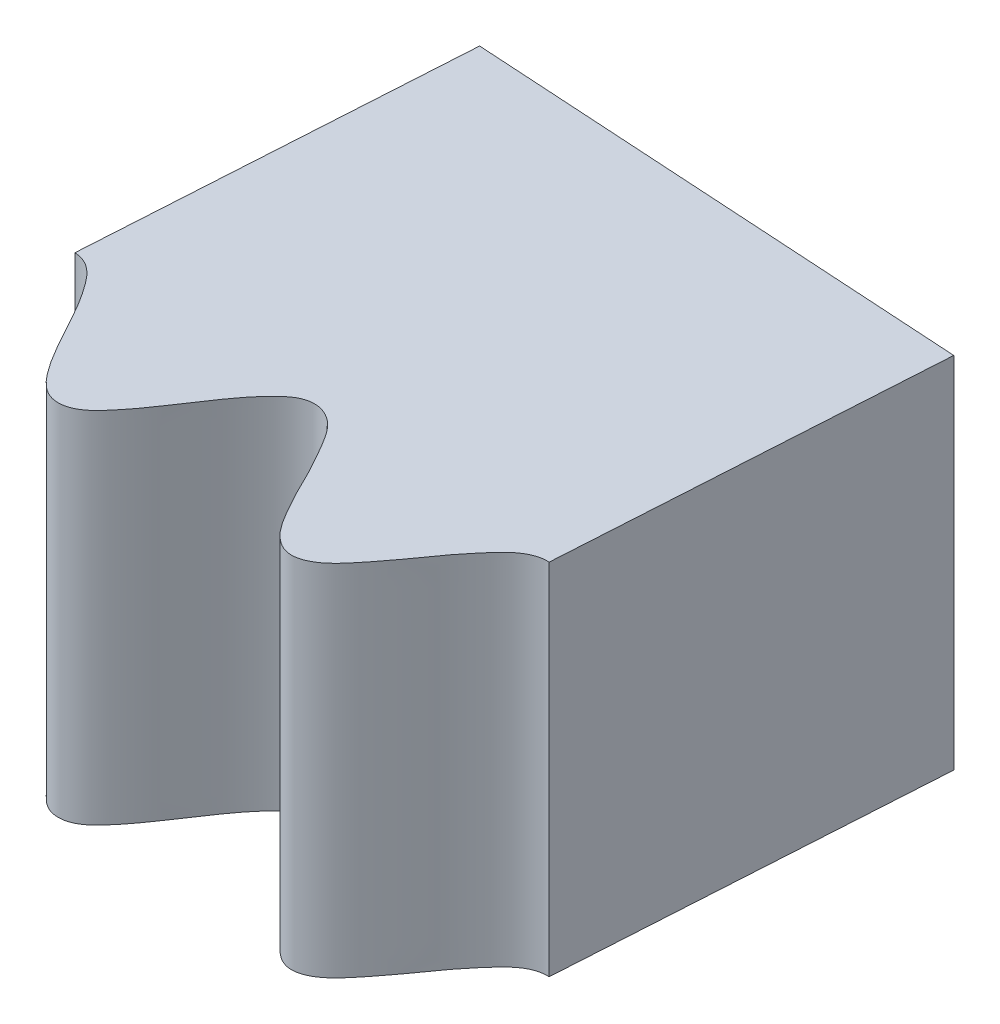
from build123d import *

# Parameters (mm, degrees)
BOSS_EXTRUDE1_DEPTH     = 4
CUT_EXTRUDE2_DEPTH      = 121.274685761
CUT_EXTRUDE2_DEPTH_BACK = 121.274685761
CUT_EXTRUDE1_DEPTH      = 121.251263566
CUT_EXTRUDE1_DEPTH_BACK = 121.251263566
CUT_EXTRUDE3_DEPTH      = 86.436238869
CUT_EXTRUDE3_DEPTH_BACK = 86.436238869


with BuildPart() as part:
    # Sketch1 → Boss-Extrude1 (new body)
    with BuildSketch(Plane(origin=(0, 0, 0), x_dir=(1, 0, 0), z_dir=(0, 1, 0))):
        with BuildLine():
            Line((0, 80.000000001), (0, 85))
            ThreePointArc((0, 85), (60.104076401, 60.1040764), (85, -1e-09))
            Line((85, -1e-09), (79.999999998, -1e-09))
            add(Edge.make_bspline(
                [(79.999999998, -1e-09), (80.045245689, 0.02681226), (80.136037734, 0.080585238), (80.334864822, 0.198976063), (80.508626367, 0.334195881), (80.753018834, 0.526004454), (80.781258066, 0.882635658), (80.459939981, 1.103766583), (80.198460731, 1.283917746), (79.891541965, 1.44569599), (79.626061012, 1.608937298), (79.381240219, 1.765048438), (79.172216457, 2.009659752), (79.273864616, 2.315204156), (79.522900146, 2.501891378), (79.779396548, 2.690833874), (80.088618496, 2.870717889), (80.350662212, 3.06392161), (80.600727145, 3.250938184), (80.728185798, 3.543289402), (80.560379021, 3.7880225), (80.345179038, 3.931341964), (80.120721915, 4.068429585), (79.89920724, 4.181739561), (79.689481725, 4.291683981), (79.493561265, 4.401042279), (79.320325812, 4.516660534), (79.117921665, 4.674691893), (79.055561951, 4.977869251), (79.314830423, 5.21984864), (79.558069697, 5.415473192), (79.844013051, 5.601917948), (80.112906693, 5.801539522), (80.362427565, 5.986752763), (80.592348669, 6.31020266), (80.364696993, 6.632082897), (80.06923695, 6.778689274), (79.775461705, 6.943332918), (79.456163372, 7.078188344), (79.194107524, 7.23317743), (78.920113249, 7.399727688), (78.842032953, 7.699819435), (79.026214893, 7.933115242), (79.22518077, 8.105822663), (79.445296584, 8.281637195), (79.703399896, 8.456254619), (79.938325413, 8.670021885), (80.221750602, 8.878963537), (80.274522022, 9.245568073), (80.009478642, 9.45007403), (79.793463584, 9.573613375), (79.549134368, 9.686889429), (79.309501257, 9.790364021), (79.065278691, 9.897929864), (78.840566054, 10.020105278), (78.602382115, 10.171484613), (78.52636273, 10.451978162), (78.702904597, 10.68553378), (78.886641465, 10.861173834), (79.091562303, 11.031391774), (79.297355716, 11.193689896), (79.503615131, 11.361173074), (79.689475466, 11.539715158), (79.867832233, 11.742233628), (79.887570214, 12.013300522), (79.69795305, 12.196804418), (79.495414452, 12.309626055), (79.268938989, 12.414026463), (79.025567335, 12.511861748), (78.761696132, 12.611495714), (78.504820249, 12.734830825), (78.231668231, 12.869982942), (78.098942061, 13.163008392), (78.281482966, 13.428010238), (78.469131216, 13.616425559), (78.681740408, 13.805685544), (78.893029523, 13.982393534), (79.105112269, 14.174667367), (79.288055774, 14.362719654), (79.479145508, 14.659947643), (79.27624125, 14.982158335), (78.955651284, 15.091459308), (78.663263398, 15.226924234), (78.371081923, 15.315930733), (78.111445613, 15.421477815), (77.872238358, 15.527590176), (77.636661624, 15.707177089), (77.646875585, 16.01419058), (77.856109832, 16.245424503), (78.062730074, 16.469057789), (78.32259806, 16.688835125), (78.554988673, 16.926051649), (78.778839306, 17.14829737), (78.912075634, 17.485848925), (78.670934329, 17.73028689), (78.41256561, 17.835491137), (78.150421173, 17.934616323), (77.904723053, 18.011215448), (77.664803855, 18.081746707), (77.426081767, 18.19040535), (77.111976282, 18.287933946), (76.969646897, 18.648997405), (77.248828953, 18.953516243), (77.438560069, 19.182392158), (77.686338139, 19.408332255), (77.902653965, 19.637457063), (78.094717908, 19.853352774), (78.24611152, 20.145230603), (78.082037928, 20.43001587), (77.780860894, 20.544801821), (77.484194275, 20.655472153), (77.136168812, 20.736047929), (76.827844649, 20.842194969), (76.527993938, 20.939774349), (76.298113812, 21.187091884), (76.410480338, 21.499269505), (76.594970673, 21.712178007), (76.78630337, 21.939912385), (77.021285595, 22.163443331), (77.218792317, 22.419877421), (77.461893887, 22.677746331), (77.448303497, 23.045296267), (77.153076804, 23.199929754), (76.918728598, 23.284193749), (76.658513621, 23.353272647), (76.404526228, 23.413581151), (76.145343984, 23.477098297), (75.902827103, 23.558398368), (75.641975749, 23.666117187), (75.518403779, 23.929148978), (75.65170721, 24.189812442), (75.802153061, 24.394689745), (75.974402682, 24.597905805), (76.148886849, 24.79347391), (76.322929574, 24.994229213), (76.474962764, 25.20233315), (76.615442928, 25.432746237), (76.587810773, 25.703122481), (76.369209202, 25.850911864), (76.150156349, 25.926849029), (75.908992617, 25.990336309), (75.652329406, 26.044424211), (75.375165743, 26.096723761), (75.100775465, 26.173579105), (74.80830432, 26.259245608), (74.626711224, 26.524771685), (74.760461834, 26.817445453), (74.912541309, 27.035583098), (75.089055839, 27.258886997), (75.266449977, 27.469600367), (75.441922708, 27.69578091), (75.589431953, 27.912744067), (75.726005506, 28.238638879), (75.470232521, 28.520720511), (75.135533121, 28.572691094), (74.824064027, 28.65532538), (74.520865628, 28.692242889), (74.246845719, 28.751101102), (73.992846341, 28.814063473), (73.729663607, 28.950014587), (73.686410062, 29.254137489), (73.852312222, 29.518191595), (74.016959925, 29.774306617), (74.234715999, 30.035870644), (74.422383859, 30.309837523), (74.604241134, 30.567578086), (74.67683809, 30.923137721), (74.396914056, 31.121988375), (74.124202012, 31.180729076), (73.848827231, 31.232827424), (73.593560519, 31.265597805), (73.345038608, 31.293396004), (73.091074869, 31.358950222), (72.76480569, 31.400453295), (72.561940597, 31.731316151), (72.784002108, 32.079688118), (72.931106897, 32.338033356), (73.135886574, 32.603567126), (73.309128972, 32.866773862), (73.460785136, 33.112741187), (73.559194686, 33.42647396), (73.348161297, 33.678441618), (73.031627448, 33.73918487), (72.72025016, 33.796658253), (72.363520149, 33.815575914), (72.041447883, 33.866570414), (71.729208096, 33.910598814), (71.459874127, 34.114240775), (71.516324478, 34.441187959), (71.661040816, 34.682898313), (71.80992108, 34.940397468), (72.002517656, 35.201336712), (72.152494495, 35.488171675), (72.347124339, 35.784337121), (72.269916041, 36.143943201), (71.952322682, 36.24496188), (71.706902462, 36.287251577), (71.43864531, 36.310095155), (71.178044095, 36.325382989), (70.911769775, 36.342928643), (70.658819662, 36.380880969), (70.383226049, 36.441666935), (70.215856424, 36.679244634), (70.30187094, 36.959095932), (70.414454611, 37.186985337), (70.548799274, 37.417024921), (70.686672589, 37.639920765), (70.823210422, 37.867848345), (70.936797017, 38.099191003), (71.035132159, 38.350497721), (70.960969456, 38.611968069), (70.720025578, 38.719552435), (70.491114279, 38.756297815), (70.242589916, 38.776942938), (69.98043373, 38.785640025), (69.698399085, 38.789016061), (69.41483162, 38.817056429), (69.111927938, 38.850634383), (68.886985529, 39.080593212), (68.967881901, 39.392046158), (69.079771742, 39.633278126), (69.214828304, 39.883840964), (69.352937434, 40.122157293), (69.4864685, 40.375372164), (69.594061493, 40.614653878), (69.671969145, 40.959313357), (69.371098967, 41.192695036), (69.032459802, 41.185756102), (68.71137334, 41.213048998), (68.406370528, 41.196755692), (68.126293019, 41.207136891), (67.865219077, 41.225035745), (67.582427167, 41.313221045), (67.487020059, 41.605211192), (67.60454995, 41.894065873), (67.722220841, 42.174872609), (67.89125167, 42.470292045), (68.028488827, 42.772654534), (68.162837614, 43.058114391), (68.172571957, 43.420785418), (67.862402258, 43.568177511), (67.583549507, 43.57823387), (67.303602841, 43.582910059), (66.99345828, 43.564723409), (66.694278866, 43.55702837), (66.424037364, 43.563845442), (66.115753527, 43.641555056), (65.980663422, 43.915215302), (66.101455704, 44.223781199), (66.211119573, 44.515165677), (66.361456012, 44.806054129), (66.48903129, 45.098499213), (66.594418223, 45.365584252), (66.637383714, 45.692265401), (66.385539876, 45.903449201), (66.063431871, 45.908498879), (65.746698606, 45.910903424), (65.392164192, 45.867660302), (65.066097446, 45.861914582), (64.75097087, 45.851071979), (64.450360211, 46.004843225), (64.449182672, 46.33662998), (64.549725793, 46.599795473), (64.651630997, 46.879236635), (64.795989494, 47.169655102), (64.893879721, 47.478175888), (65.034123987, 47.803638888), (64.895643776, 48.144374734), (64.565333634, 48.188709168), (64.316298385, 48.187739634), (64.04814991, 48.163653793), (63.78885311, 48.133456448), (63.523577324, 48.104497492), (63.267879739, 48.097948911), (62.98591764, 48.109955072), (62.779835801, 48.314860003), (62.815947897, 48.605395994), (62.887248588, 48.849373196), (62.9796063, 49.099246668), (63.076679553, 49.342697673), (63.17156386, 49.590872067), (63.243252589, 49.838424215), (63.296454845, 50.102988739), (63.17801499, 50.347608546), (62.922049762, 50.411718998), (62.690235372, 50.408156103), (62.441901664, 50.385331778), (62.182217986, 50.348373792), (61.903881839, 50.302723737), (61.619753243, 50.281097135), (61.315620597, 50.261566292), (61.054163638, 50.448970691), (61.079747775, 50.769739474), (61.148048266, 51.026736054), (61.237543235, 51.296944603), (61.332170984, 51.555622776), (61.419703105, 51.828178157), (61.4841107, 52.082508), (61.50098524, 52.435459795), (61.164159709, 52.613050426), (60.831870053, 52.547412628), (60.510922484, 52.518535224), (60.213382179, 52.449525403), (59.935758038, 52.411115833), (59.675540291, 52.383404096), (59.381734936, 52.421149801), (59.237066838, 52.69212413), (59.302667872, 52.997028108), (59.369753434, 53.293936256), (59.484989475, 53.614351336), (59.567501467, 53.93570383), (59.650488663, 54.240610984), (59.596680581, 54.598700646), (59.266395013, 54.691392062), (58.988097032, 54.649340325), (58.716336171, 54.613994972), (58.4034352, 54.522830082), (58.08058627, 54.493558174), (57.692145499, 54.368585848), (57.329587976, 54.627991743), (57.425029251, 55.043431179), (57.471237245, 55.329001576), (57.574869246, 55.652697061), (57.646602495, 55.957154431), (57.705475834, 56.24115886), (57.690440693, 56.569205491), (57.406058763, 56.734010088), (57.087774426, 56.682697239), (56.775559955, 56.630292284), (56.433849325, 56.52601138), (56.113771889, 56.463801221), (55.805297995, 56.398370064), (55.482559706, 56.497618404), (55.423781795, 56.824152619), (55.477101676, 57.100783628), (55.528933062, 57.393672913), (55.620668354, 57.704747888), (55.663497053, 58.025579492), (55.745094781, 58.370451402), (55.549550167, 58.681963741), (55.21655962, 58.668266946), (54.971476115, 58.624067591), (54.711583889, 58.553784189), (54.461470101, 58.479019187), (54.205253121, 58.404435527), (53.954577306, 58.353585014), (53.674813997, 58.31644657), (53.436281637, 58.482452799), (53.421394062, 58.774845695), (53.44924534, 59.02749757), (53.496809857, 59.289612651), (53.550133526, 59.546221682), (53.600481296, 59.807102236), (53.628093932, 60.063342128), (53.634546779, 60.333125796), (53.475428509, 60.553462414), (53.212219304, 60.572150989), (52.984545386, 60.528388076), (52.743947827, 60.462787808), (52.494627015, 60.3812977), (52.228446468, 60.288008607), (51.952389844, 60.217372149), (51.656269151, 60.145325943), (51.366241879, 60.284481724), (51.335736421, 60.604819947), (51.358372286, 60.869772427), (51.399586403, 61.151416539), (51.44785755, 61.422596745), (51.486731117, 61.706211191), (51.505996303, 61.967861454), (51.461325044, 62.318381351), (51.09877836, 62.434784842), (50.782934814, 62.312442736), (50.471877669, 62.228272084), (50.190841099, 62.108643347), (49.924104445, 62.022608378), (49.672652083, 61.950131307), (49.376755818, 61.936284805), (49.187231355, 62.178021074), (49.198889742, 62.489684375), (49.213398565, 62.793731107), (49.271244417, 63.12928889), (49.296700591, 63.460087375), (49.325480454, 63.77477288), (49.21030822, 64.118078679), (48.868944737, 64.152008417), (48.602176935, 64.062269604), (48.340682387, 63.980270448), (48.048365703, 63.836155874), (47.735504587, 63.751266543), (47.37466632, 63.560740796), (46.9725715, 63.753248279), (46.994422507, 64.178949461), (46.990339718, 64.468205335), (47.036188185, 64.804978667), (47.053963178, 65.117266993), (47.062625247, 65.407180004), (46.990853823, 65.727632045), (46.682174276, 65.840550486), (46.377635776, 65.7347477), (46.079264569, 65.62892342), (45.760853481, 65.466889349), (45.456441421, 65.350043439), (45.16401594, 65.232040398), (44.828946477, 65.273738017), (44.714359464, 65.585104767), (44.718832825, 65.866792029), (44.719017085, 66.164232094), (44.75534111, 66.486510807), (44.741807321, 66.809905383), (44.762279017, 67.163707211), (44.515611616, 67.436531012), (44.190058366, 67.3652191), (43.956373369, 67.279132929), (43.712634074, 67.164787478), (43.479302883, 67.047726521), (43.239929731, 66.929784343), (43.001892344, 66.836176964), (42.732828291, 66.751022349), (42.469093094, 66.87308586), (42.403658202, 67.158451451), (42.387213818, 67.4121013), (42.388539918, 67.678493755), (42.396493789, 67.940463876), (42.40077523, 68.206123867), (42.383472779, 68.463265783), (42.34298015, 68.730071357), (42.148018192, 68.919429969), (41.885562489, 68.892128824), (41.668946799, 68.809495607), (41.443395826, 68.703112626), (41.212013365, 68.579566431), (40.96607618, 68.441472842), (40.706479368, 68.323972781), (40.427368107, 68.201600301), (40.117582852, 68.288279284), (40.031914692, 68.598453633), (40.008198153, 68.863311567), (39.999879148, 69.147833628), (40.000326999, 69.423276194), (39.989360857, 69.709332223), (39.96289827, 69.970352795), (39.858038527, 70.307790425), (39.480786488, 70.359469914), (39.190985799, 70.184140804), (38.89927039, 70.047234387), (38.64327671, 69.88062159), (38.3955322, 69.749575352), (38.160485476, 69.634535127), (37.87148896, 69.569517137), (37.642866738, 69.774670311), (37.600228243, 70.083623203), (37.561719483, 70.385570213), (37.560417529, 70.726074947), (37.528044413, 71.056268277), (37.50174248, 71.371170573), (37.328705545, 71.689261337), (36.986636303, 71.663398459), (36.739504285, 71.528699238), (36.496221431, 71.402537782), (36.233370927, 71.209852372), (35.940003752, 71.071924939), (35.617731878, 70.821634798), (35.188317208, 70.941394628), (35.135914015, 71.364422839), (35.081664498, 71.648575298), (35.068336348, 71.988193789), (35.031613, 72.298824349), (34.989800606, 72.585837082), (34.863473639, 72.888957759), (34.539875547, 72.946559075), (34.258336131, 72.789481115), (33.982874047, 72.633452928), (33.69743726, 72.418589013), (33.417939982, 72.250657655), (33.150448114, 72.083668194), (32.813228394, 72.066548131), (32.646313946, 72.353286694), (32.601804867, 72.631471284), (32.550336403, 72.924424563), (32.530145473, 73.248114739), (32.460660414, 73.564246107), (32.419384056, 73.916227763), (32.129088731, 74.142073412), (31.82086455, 74.015313161), (31.60567846, 73.889955858), (31.385497991, 73.735022686), (31.176039048, 73.579222612), (30.960782956, 73.42150553), (30.742616643, 73.287985499), (30.492427221, 73.157402091), (30.211502648, 73.231814046), (30.097508644, 73.501481643), (30.037268253, 73.748422444), (29.992315642, 74.010998074), (29.954658042, 74.270369455), (29.912743066, 74.532736938), (29.851051252, 74.782967752), (29.764843496, 75.038688478), (29.53996167, 75.191315518), (29.286234053, 75.118854185), (29.087258349, 74.999861432), (28.883607213, 74.855928133), (28.677193544, 74.694079739), (28.458972396, 74.515377558), (28.223723115, 74.354584073), (27.970101939, 74.185603544), (27.649971371, 74.217172035), (27.511743493, 74.507758018), (27.442395163, 74.764473831), (27.384795805, 75.043228783), (27.337406753, 75.314564526), (27.276934103, 75.594370471), (27.205547796, 75.846830374), (27.043685678, 76.160932864), (26.663190896, 76.146318097), (26.408238511, 75.923329268), (26.144728465, 75.737846918), (25.921555913, 75.529312508), (25.700331139, 75.357236774), (25.488831829, 75.203128833), (25.215516074, 75.088914894), (24.954742662, 75.251251498), (24.859102836, 75.548106605), (24.768746562, 75.838779385), (24.708336362, 76.173885005), (24.619117595, 76.493440424), (24.538533038, 76.798991364), (24.312889041, 77.082202066), (23.980507641, 76.997332403), (23.760520388, 76.821765541), (23.542841255, 76.655275136), (23.317443511, 76.41987354), (23.05248409, 76.233098859), (22.778570677, 75.930649265), (22.334883704, 75.974022598), (22.209818555, 76.381524341), (22.107050653, 76.651939556), (22.034950856, 76.98408407), (21.944844987, 77.283618511), (21.85382858, 77.559010231), (21.67678445, 77.835589376), (21.348100176, 77.836123379), (21.098114278, 77.63254298), (20.853931093, 77.431051722), (20.610141459, 77.169886495), (20.364051347, 76.955972199), (20.129620698, 76.745070208), (19.80049697, 76.669652647), (19.586326699, 76.923050617), (19.494187566, 77.189280038), (19.39263022, 77.468845294), (19.316537826, 77.78411177), (19.193212765, 78.083374438), (19.091442516, 78.422841138), (18.766339743, 78.59484643), (18.484809867, 78.416489384), (18.294661004, 78.255669868), (18.104729435, 78.064856542), (17.925507042, 77.875051258), (17.740908458, 77.682351424), (17.549242091, 77.51297568), (17.32552918, 77.34093119), (17.035950982, 77.36543062), (16.876861516, 77.61120651), (16.774655492, 77.843935091), (16.684790032, 78.094715668), (16.602665168, 78.343607441), (16.515827339, 78.594710514), (16.411620638, 78.830427088), (16.282317133, 79.067293022), (16.03434836, 79.178550995), (15.797058214, 79.063131174), (15.621768274, 78.91139442), (15.44620481, 78.734284142), (15.271031707, 78.539051232), (15.087157138, 78.325170234), (14.883403318, 78.125968954), (14.662978378, 77.915514764), (14.342229502, 77.891013569), (14.155641889, 78.153181879), (14.042768883, 78.39395539), (13.937639299, 78.658473406), (13.843853237, 78.917457921), (13.735711506, 79.182512034), (13.621570524, 79.41874037), (13.407624115, 79.699963936), (13.03544776, 79.619498862), (12.82309022, 79.355625944), (12.595792274, 79.127202993), (12.412221591, 78.883084121), (12.22423889, 78.675205267), (12.042712263, 78.486716073), (11.793383645, 78.326769517), (11.508378973, 78.441370698), (11.362651894, 78.717076906), (11.223174991, 78.987715121), (11.105529211, 79.307096222), (10.962105974, 79.606573301), (10.829815366, 79.892994359), (10.558205816, 80.133548531), (10.246005426, 79.990729165), (10.058851809, 79.783471847), (9.875842031, 79.572296322), (9.72038638, 79.364176326), (9.570558679, 79.17205114), (9.424599332, 78.999740208), (9.279324966, 78.85318375), (9.066797162, 78.699742192), (8.770683999, 78.772348614), (8.611723062, 79.063103597), (8.459139485, 79.334481921), (8.332868894, 79.636588543), (8.190882641, 79.922315645), (8.054008316, 80.174716955), (7.831380781, 80.417620704), (7.507719009, 80.360441639), (7.296805891, 80.116939606), (7.091370269, 79.875852722), (6.896606907, 79.576467885), (6.691416289, 79.322992764), (6.497162946, 79.074622415), (6.186138445, 78.943183498), (5.931218184, 79.155549889), (5.794249565, 79.401729892), (5.645688632, 79.65941513), (5.516007026, 79.956677544), (5.342589021, 80.229979148), (5.183417173, 80.546616074), (4.833385009, 80.659554857), (4.587103595, 80.435020235), (4.427769527, 80.243624954), (4.273857842, 80.022729251), (4.130317555, 79.804685816), (3.981985488, 79.582858554), (3.822642565, 79.382772891), (3.63220397, 79.174496092), (3.342769981, 79.148335866), (3.143421126, 79.362759352), (3.002347586, 79.574180977), (2.870324566, 79.805625166), (2.746149925, 80.036227821), (2.617246467, 80.2691377), (2.4731671, 80.481455918), (2.298316642, 80.705055998), (2.002698402, 80.761653221), (1.777664065, 80.551009489), (1.61646107, 80.336886503), (1.462597325, 80.098665091), (1.320217667, 79.861108113), (1.166402014, 79.623649343), (1.008799898, 79.406079857), (0.779772274, 79.202562499), (0.498937662, 79.274111558), (0.328371779, 79.48655789), (0.197027916, 79.668726086), (0.080042944, 79.864661174), (0.026675335, 79.954985372), (0, 80.000000001)],
                knots=[0.076327262, 0.076327262, 0.076327262, 0.076327262, 0.076327262, 0.0774294, 0.078531539, 0.079633678, 0.080735817, 0.082434062, 0.084132308, 0.085531434, 0.086930561, 0.088329688, 0.089728814, 0.090836684, 0.091944554, 0.093505173, 0.095065793, 0.096626412, 0.098187032, 0.099365662, 0.100544292, 0.101706021, 0.102867749, 0.104029477, 0.105191206, 0.106130215, 0.107069225, 0.108008235, 0.108947245, 0.110462803, 0.111978362, 0.11344534, 0.114912318, 0.116379296, 0.117846275, 0.119324241, 0.120802208, 0.122308259, 0.123814311, 0.125320363, 0.126826414, 0.127955081, 0.129083747, 0.130326681, 0.131569616, 0.13281255, 0.134055484, 0.135754286, 0.137453087, 0.138623474, 0.13979386, 0.140964247, 0.142134633, 0.143304668, 0.144474702, 0.145644736, 0.14681477, 0.147984479, 0.149154188, 0.150323898, 0.151493607, 0.15266292, 0.153832234, 0.155001547, 0.156170861, 0.157210952, 0.158251044, 0.159291135, 0.160331227, 0.161631572, 0.162931917, 0.164232262, 0.165532607, 0.166772381, 0.168012155, 0.169251929, 0.170491703, 0.171731534, 0.172971366, 0.174211198, 0.17545103, 0.17713094, 0.178810849, 0.180043573, 0.181276297, 0.182509021, 0.183741745, 0.184859129, 0.185976513, 0.187466593, 0.188956673, 0.190446753, 0.191936833, 0.19333534, 0.194733848, 0.195964972, 0.197196096, 0.19842722, 0.199658345, 0.200586919, 0.201515493, 0.203372641, 0.204880757, 0.206388874, 0.207789487, 0.209190099, 0.210590712, 0.211991325, 0.213153099, 0.214314872, 0.215865314, 0.217415755, 0.218966197, 0.220516639, 0.221743319, 0.222969998, 0.224287452, 0.225604906, 0.22692236, 0.228239814, 0.229921197, 0.23160258, 0.232772967, 0.233943353, 0.23511374, 0.236284126, 0.23745416, 0.238624195, 0.239794229, 0.240964263, 0.242133972, 0.243303681, 0.244473391, 0.2456431, 0.246812413, 0.247981727, 0.24915104, 0.250320354, 0.251360445, 0.252400537, 0.253440628, 0.25448072, 0.255781065, 0.25708141, 0.258381755, 0.2596821, 0.260921874, 0.262161648, 0.263401422, 0.264641196, 0.265881027, 0.267120859, 0.268360691, 0.269600523, 0.271280433, 0.272960342, 0.274193066, 0.27542579, 0.276658514, 0.277891238, 0.279008622, 0.280126006, 0.281616086, 0.283106166, 0.284596246, 0.286086326, 0.287484833, 0.288883341, 0.290114465, 0.291345589, 0.292576713, 0.293807837, 0.294736411, 0.295664985, 0.297522134, 0.29903025, 0.300538367, 0.30193898, 0.303339592, 0.304740205, 0.306140818, 0.307302591, 0.308464365, 0.310014806, 0.311565248, 0.31311569, 0.314666132, 0.315892811, 0.317119491, 0.318436945, 0.319754399, 0.321071853, 0.322389307, 0.32407069, 0.325752073, 0.32692246, 0.328092846, 0.329263233, 0.330433619, 0.331603653, 0.332773688, 0.333943722, 0.335113756, 0.336283465, 0.337453174, 0.338622883, 0.339792593, 0.340961906, 0.34213122, 0.343300533, 0.344469847, 0.345509938, 0.34655003, 0.347590121, 0.348630213, 0.349930558, 0.351230903, 0.352531248, 0.353831593, 0.355071367, 0.356311141, 0.357550915, 0.358790689, 0.36003052, 0.361270352, 0.362510184, 0.363750016, 0.365429925, 0.367109835, 0.368342559, 0.369575283, 0.370808007, 0.372040731, 0.373158115, 0.374275499, 0.375765579, 0.377255659, 0.378745739, 0.380235819, 0.381634326, 0.383032834, 0.384263958, 0.385495082, 0.386726206, 0.38795733, 0.389814478, 0.390743052, 0.391671626, 0.393179743, 0.39468786, 0.396088473, 0.397489085, 0.398889698, 0.400290311, 0.401452084, 0.402613858, 0.404164299, 0.405714741, 0.407265183, 0.408815625, 0.410042304, 0.411268984, 0.412586438, 0.413903892, 0.415221346, 0.4165388, 0.418220183, 0.419901566, 0.421071953, 0.422242339, 0.423412726, 0.424583112, 0.425753146, 0.426923181, 0.428093215, 0.429263249, 0.430432958, 0.431602667, 0.432772376, 0.433942086, 0.435111399, 0.436280713, 0.437450026, 0.43861934, 0.439659431, 0.440699523, 0.441739614, 0.442779706, 0.444080051, 0.445380396, 0.446680741, 0.447981086, 0.44922086, 0.450460634, 0.451700408, 0.452940181, 0.454180013, 0.455419845, 0.456659677, 0.457899509, 0.459579418, 0.461259328, 0.462492052, 0.463724776, 0.4649575, 0.466190224, 0.467307608, 0.468424992, 0.469915072, 0.471405152, 0.472895232, 0.474385312, 0.475783819, 0.477182327, 0.478413451, 0.479644575, 0.480875699, 0.482106823, 0.483963971, 0.485821119, 0.487329236, 0.488837353, 0.490237965, 0.491638578, 0.493039191, 0.494439804, 0.495601577, 0.496763351, 0.498313792, 0.499864234, 0.501414676, 0.502965118, 0.504191797, 0.505418477, 0.506735931, 0.508053385, 0.509370839, 0.510688293, 0.512369676, 0.514051059, 0.515221445, 0.516391832, 0.517562219, 0.518732605, 0.519902639, 0.521072674, 0.522242708, 0.523412742, 0.524582451, 0.52575216, 0.526921869, 0.528091578, 0.529260892, 0.530430206, 0.531599519, 0.532768833, 0.533808924, 0.534849016, 0.535889107, 0.536929199, 0.538229544, 0.539529889, 0.540830234, 0.542130579, 0.543370353, 0.544610127, 0.545849901, 0.547089674, 0.548329506, 0.549569338, 0.55080917, 0.552049002, 0.553728911, 0.555408821, 0.556641545, 0.557874269, 0.559106993, 0.560339717, 0.561457101, 0.562574485, 0.564064565, 0.565554645, 0.567044725, 0.568534805, 0.569933312, 0.571331819, 0.572562944, 0.573794068, 0.575025192, 0.576256316, 0.578113464, 0.579970612, 0.581478729, 0.582986846, 0.584387458, 0.585788071, 0.587188684, 0.588589297, 0.58975107, 0.590912844, 0.592463285, 0.594013727, 0.595564169, 0.59711461, 0.59834129, 0.59956797, 0.600885424, 0.602202878, 0.603520332, 0.604837786, 0.606519169, 0.608200552, 0.609370938, 0.610541325, 0.611711712, 0.612882098, 0.614052132, 0.615222167, 0.616392201, 0.617562235, 0.618731944, 0.619901653, 0.621071362, 0.622241071, 0.623410385, 0.624579698, 0.625749012, 0.626918325, 0.627958417, 0.628998509, 0.6300386, 0.631078692, 0.632379037, 0.633679382, 0.634979727, 0.636280072, 0.637519846, 0.63875962, 0.639999394, 0.641239167, 0.642478999, 0.643718831, 0.644958663, 0.646198495, 0.647878404, 0.649558314, 0.650791038, 0.652023762, 0.653256486, 0.65448921, 0.655606594, 0.656723978, 0.658214058, 0.659704138, 0.661194218, 0.662684298, 0.664082805, 0.665481312, 0.666712437, 0.667943561, 0.669174685, 0.670405809, 0.672262957, 0.674120105, 0.675628222, 0.677136339, 0.678536951, 0.679937564, 0.681338177, 0.68273879, 0.683900563, 0.685062337, 0.686612778, 0.68816322, 0.689713662, 0.691264103, 0.692490783, 0.693717463, 0.695034917, 0.696352371, 0.697669825, 0.698987279, 0.700668662, 0.702350045, 0.703520431, 0.704690818, 0.705861204, 0.707031591, 0.708201625, 0.70937166, 0.710541694, 0.711711728, 0.712881437, 0.714051146, 0.715220855, 0.716390564, 0.717559878, 0.718729191, 0.719898505, 0.721067818, 0.72210791, 0.723148002, 0.724188093, 0.725228185, 0.72652853, 0.727828875, 0.72912922, 0.730429565, 0.731669339, 0.732909113, 0.734148887, 0.73538866, 0.736628492, 0.737868324, 0.739108156, 0.740347988, 0.742027897, 0.743707807, 0.744940531, 0.746173255, 0.747405979, 0.748638703, 0.749756087, 0.750873471, 0.752363551, 0.753853631, 0.755343711, 0.756833791, 0.758232298, 0.759630805, 0.76086193, 0.762093054, 0.763324178, 0.764555302, 0.76641245, 0.768269598, 0.769777715, 0.771285831, 0.772686444, 0.774087057, 0.77548767, 0.776888283, 0.778050056, 0.77921183, 0.780762271, 0.782312713, 0.783863155, 0.785413596, 0.786640276, 0.787866956, 0.78918441, 0.790501864, 0.791819318, 0.793136772, 0.794818155, 0.796499538, 0.797669924, 0.798840311, 0.800010697, 0.801181084, 0.802351118, 0.803521152, 0.804691187, 0.805861221, 0.80703093, 0.808200639, 0.809370348, 0.810540057, 0.811709371, 0.812878684, 0.814047998, 0.815217311, 0.816257403, 0.817297495, 0.818337586, 0.819377678, 0.820678023, 0.821978368, 0.823278713, 0.824579058, 0.825818832, 0.827058606, 0.828298379, 0.829538153, 0.830777985, 0.832017817, 0.833257649, 0.834497481, 0.83617739, 0.8378573, 0.839090024, 0.840322748, 0.841555472, 0.842788196, 0.84390558, 0.845022964, 0.846513044, 0.848003124, 0.849493204, 0.850983284, 0.852381791, 0.853780298, 0.855011423, 0.856242547, 0.857473671, 0.858704795, 0.859633369, 0.860561943, 0.861490517, 0.862419091, 0.863927208, 0.865435324, 0.866835937, 0.86823655, 0.869637163, 0.871037776, 0.872199549, 0.873361323, 0.874911764, 0.876462206, 0.878012648, 0.879563089, 0.880789769, 0.882016449, 0.883333903, 0.884651357, 0.885968811, 0.887286265, 0.888967648, 0.890649031, 0.891819417, 0.892989804, 0.89416019, 0.895330577, 0.896500611, 0.897670645, 0.89884068, 0.900010714, 0.901180423, 0.902350132, 0.903519841, 0.90468955, 0.905858864, 0.907028177, 0.908197491, 0.909366804, 0.910606707, 0.911846609, 0.913086512, 0.914326415, 0.915566002, 0.916805589, 0.918045177, 0.919284764, 0.920381275, 0.921477785, 0.922574296, 0.923670806, 0.923670806, 0.923670806, 0.923670806, 0.923670806], degree=4))
        make_face()
    extrude(amount=BOSS_EXTRUDE1_DEPTH)

    # Sketch3 → Cut-Extrude2 (cut, two sides)
    with BuildSketch(Plane(origin=(0, 4, 0), x_dir=(1, 0, 0), z_dir=(0, 1, 0))) as cut_extrude2_sk:
        with BuildLine():
            add(Edge.make_bspline(
                [(2.113687284, 80.71846083), (2.05626031, 80.720631066), (1.931042158, 80.694448641), (1.77131819, 80.54258038), (1.61646107, 80.336886503), (1.462597325, 80.098665091), (1.320217667, 79.861108113), (1.166402014, 79.623649343), (1.008799898, 79.406079857), (0.779772274, 79.202562499), (0.498937662, 79.274111558), (0.328371779, 79.48655789), (0.197027916, 79.668726086), (0.080042944, 79.864661174), (0.026675335, 79.954985372), (0, 80.000000001)],
                knots=[0.909562043, 0.909562043, 0.909562043, 0.909562043, 0.909562043, 0.910606707, 0.911846609, 0.913086512, 0.914326415, 0.915566002, 0.916805589, 0.918045177, 0.919284764, 0.920381275, 0.921477785, 0.922574296, 0.923670806, 0.923670806, 0.923670806, 0.923670806, 0.923670806], degree=4))
            Line((2.113687284, 80.71846083), (2.37353017, 84.966854447))
            ThreePointArc((2.37353017, 84.966854447), (1.186880796, 84.991713208), (0, 85))
            Line((0, 85), (0, 80.000000001))
        make_face()
    extrude(amount=CUT_EXTRUDE2_DEPTH, mode=Mode.SUBTRACT)
    extrude(cut_extrude2_sk.sketch, amount=-CUT_EXTRUDE2_DEPTH_BACK, mode=Mode.SUBTRACT)

    # Sketch2 → Cut-Extrude1 (cut, two sides)
    with BuildSketch(Plane(origin=(0, 4, 0), x_dir=(1, 0, 0), z_dir=(0, 1, 0))) as cut_extrude1_sk:
        with BuildLine():
            Line((84.999999996, -247.398460181), (85, -1e-09))
            ThreePointArc((85, -1e-09), (62.86858458, 57.206127931), (7.999033578, 84.62278335))
            Line((7.999033578, 84.62278335), (7.73922066, 80.374879546))
            Line((7.73922066, 80.374879546), (-7.364093469, -166.562132669))
            Line((-7.364093469, -166.562132669), (-333.230659749, -538.899309671))
            Line((-333.230659749, -538.899309671), (-240.866566284, -619.735637183))
            Line((-240.866566284, -619.735637183), (84.999999996, -247.398460181))
        make_face()
    extrude(amount=CUT_EXTRUDE1_DEPTH, mode=Mode.SUBTRACT)
    extrude(cut_extrude1_sk.sketch, amount=-CUT_EXTRUDE1_DEPTH_BACK, mode=Mode.SUBTRACT)

    # Sketch4 → Cut-Extrude3 (cut, two sides)
    with BuildSketch(Plane(origin=(0, 4, 0), x_dir=(1, 0, 0), z_dir=(0, 1, 0))) as cut_extrude3_sk:
        with BuildLine():
            Line((2.37353017, 84.966854447), (7.999033578, 84.62278335))
            ThreePointArc((7.999033578, 84.62278335), (5.189134408, 84.841457343), (2.37353017, 84.966854447))
        make_face()
    extrude(amount=CUT_EXTRUDE3_DEPTH, mode=Mode.SUBTRACT)
    extrude(cut_extrude3_sk.sketch, amount=-CUT_EXTRUDE3_DEPTH_BACK, mode=Mode.SUBTRACT)


solid = part.part
